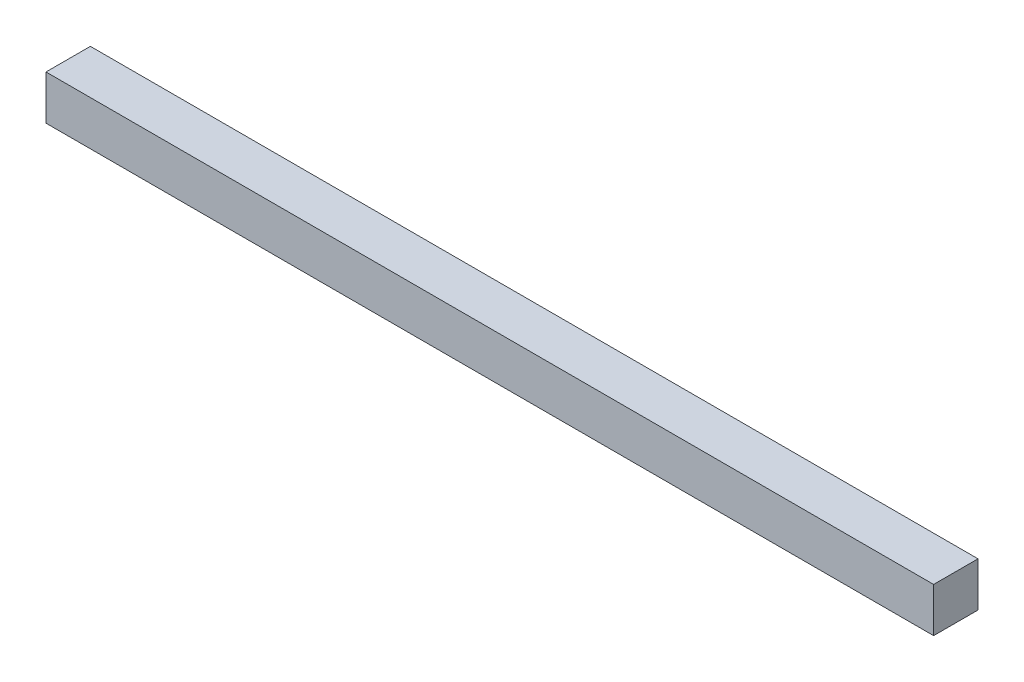
from build123d import *

# Parameters (mm, degrees)
SKETCH1_W           = 200
SKETCH1_H           = 10
BOSS_EXTRUDE1_DEPTH = 10


with BuildPart() as part:
    # Sketch1 → Boss-Extrude1 (new body)
    with BuildSketch(Plane(origin=(0, 0, 0), x_dir=(1, 0, 0), z_dir=(0, 1, 0))):
        with Locations((100, 5)):
            Rectangle(SKETCH1_W, SKETCH1_H)
    extrude(amount=BOSS_EXTRUDE1_DEPTH)


solid = part.part
